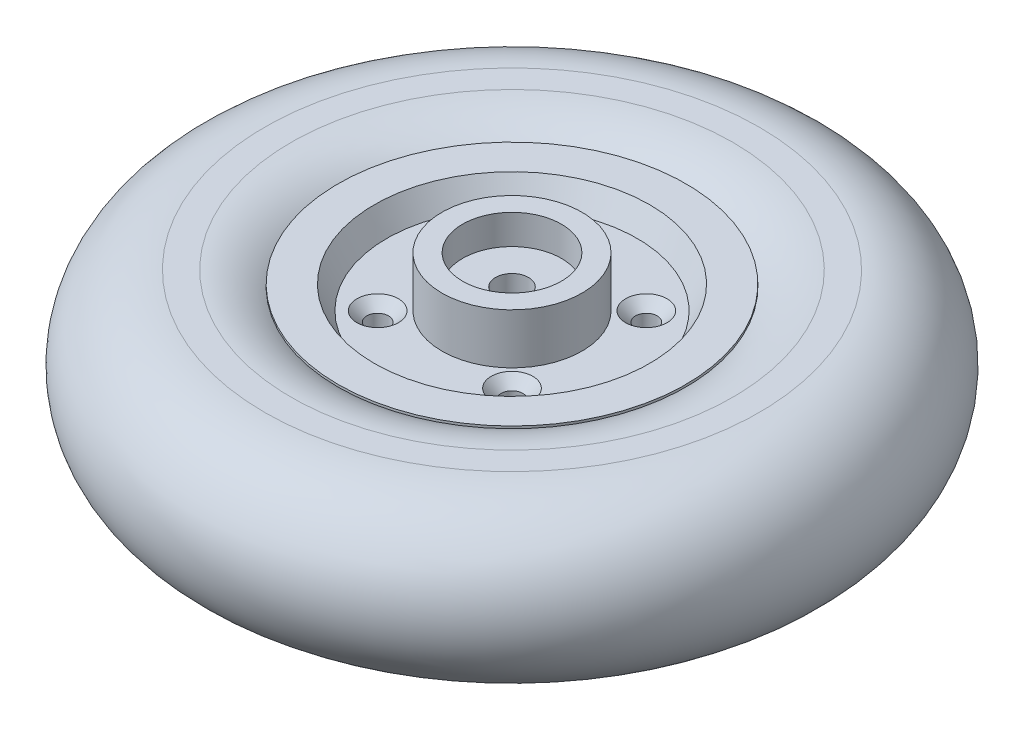
from build123d import *

# Parameters (mm, degrees)
HOLE_WIZARD_M6_1_D           = 6.6
HOLE_WIZARD_M6_1_CSINK_D     = 12.6
HOLE_WIZARD_M6_1_CSINK_ANGLE = 90


with BuildPart() as part:
    # 草圖1 → 旋轉1 (revolve)
    with BuildSketch(Plane.XY):
        Polygon((15, 29.5), (21.25, 29.5), (21.25, 14.25), (38, 14.25), (41.75, 21.25), (52.75, 21.25), (52.75, -21.25), (41.75, -21.25), (38, -14.25), (21.25, -14.25), (21.25, -29.5), (15, -29.5), (15, -20.5), (5, -20.5), (5, 20.5), (15, 20.5), align=None)
    revolve(axis=Axis((0, 152.231132075, 0), (0, -1, 0)))

    # 草圖2 → 旋轉2 (revolve)
    with BuildSketch(Plane.XY):
        with BuildLine():
            Line((-75, 25), (-67, 25))
            ThreePointArc((-67, 25), (-42, 0), (-67, -25))
            Line((-67, -25), (-75, -25))
            ThreePointArc((-75, -25), (-100, 0), (-75, 25))
        make_face()
    revolve(axis=Axis((0, 0, 0), (0, 1, 0)))

    # M6 平錐坑頭螺釘的錐孔1 (through all)
    with Locations(Plane(origin=(0, 14.25, 0), x_dir=(1, 0, 0), z_dir=(0, 1, 0))):
        with Locations((-20.375, -20.375), (-20.375, 20.375), (20.375, -20.375), (20.375, 20.375)):
            CounterSinkHole(HOLE_WIZARD_M6_1_D / 2, HOLE_WIZARD_M6_1_CSINK_D / 2, counter_sink_angle=HOLE_WIZARD_M6_1_CSINK_ANGLE)


solid = part.part
